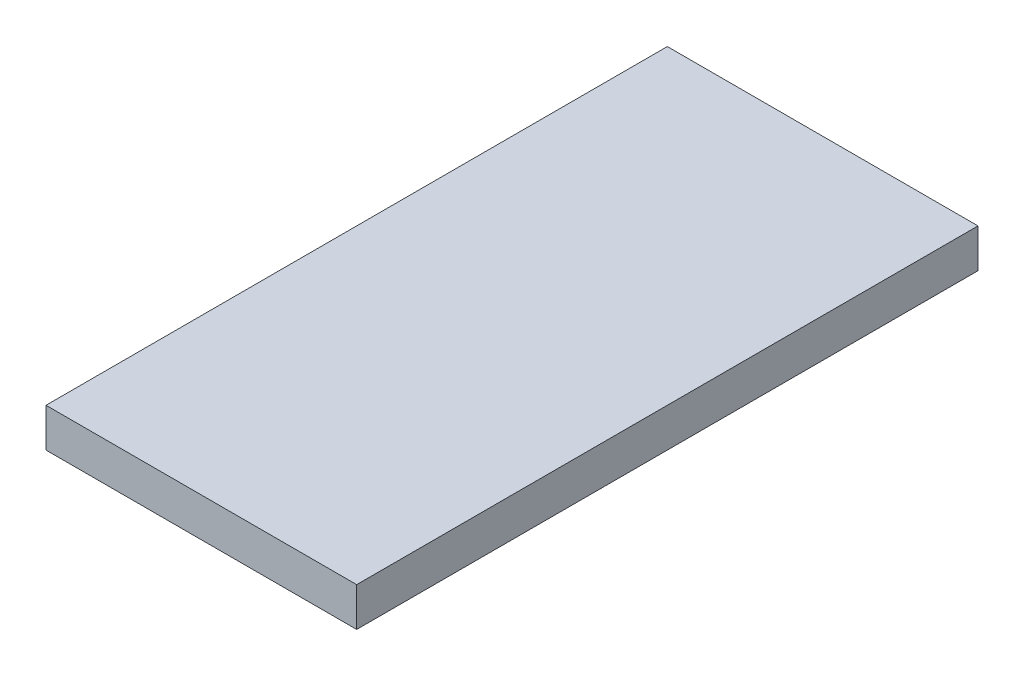
from build123d import *

# Parameters (mm, degrees)
SKETCH1_W           = 609.6
SKETCH1_H           = 1219.2
BOSS_EXTRUDE1_DEPTH = 38.1


with BuildPart() as part:
    # Sketch1 → Boss-Extrude1 (new body, symmetric)
    with BuildSketch(Plane(origin=(0, 0, 0), x_dir=(1, 0, 0), z_dir=(0, 1, 0))):
        Rectangle(SKETCH1_W, SKETCH1_H)
    extrude(amount=BOSS_EXTRUDE1_DEPTH, both=True)


solid = part.part
